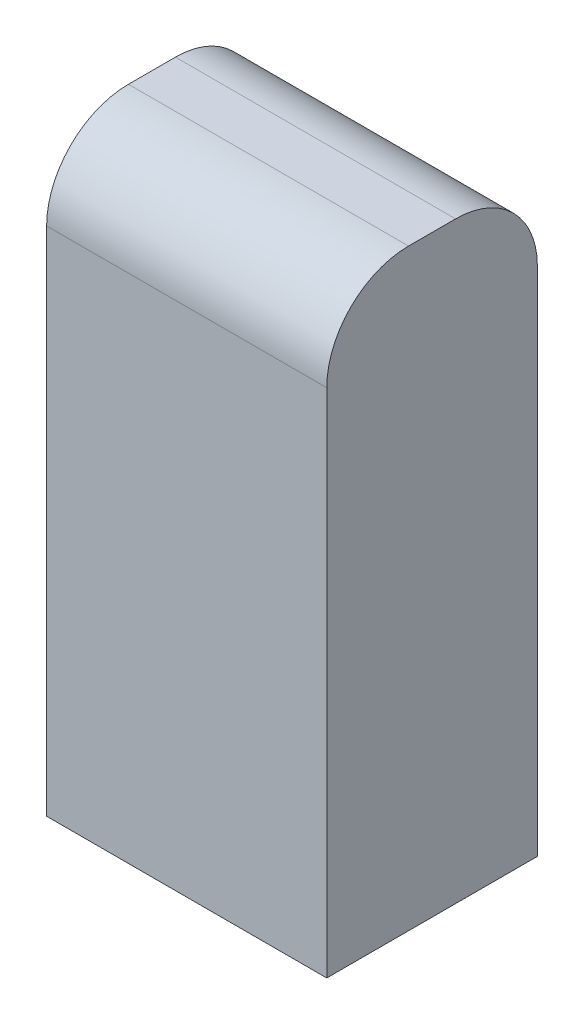
from build123d import *

# Parameters (mm, degrees)
SKETCH1_W           = 34.798
SKETCH1_H           = 26.162
BOSS_EXTRUDE1_DEPTH = 73.66
FILLET1_R           = 10.16


with BuildPart() as part:
    # Sketch1 → Boss-Extrude1 (new body)
    with BuildSketch(Plane(origin=(0, 0, 0), x_dir=(1, 0, 0), z_dir=(0, 1, 0))):
        Rectangle(SKETCH1_W, SKETCH1_H)
    extrude(amount=BOSS_EXTRUDE1_DEPTH)

    # Fillet1
    fillet1_edges = [part.edges().sort_by_distance(p)[0] for p in [
        (0, 73.66, 13.081),
        (0, 73.66, -13.081),
    ]]
    fillet(fillet1_edges, radius=FILLET1_R)


solid = part.part
